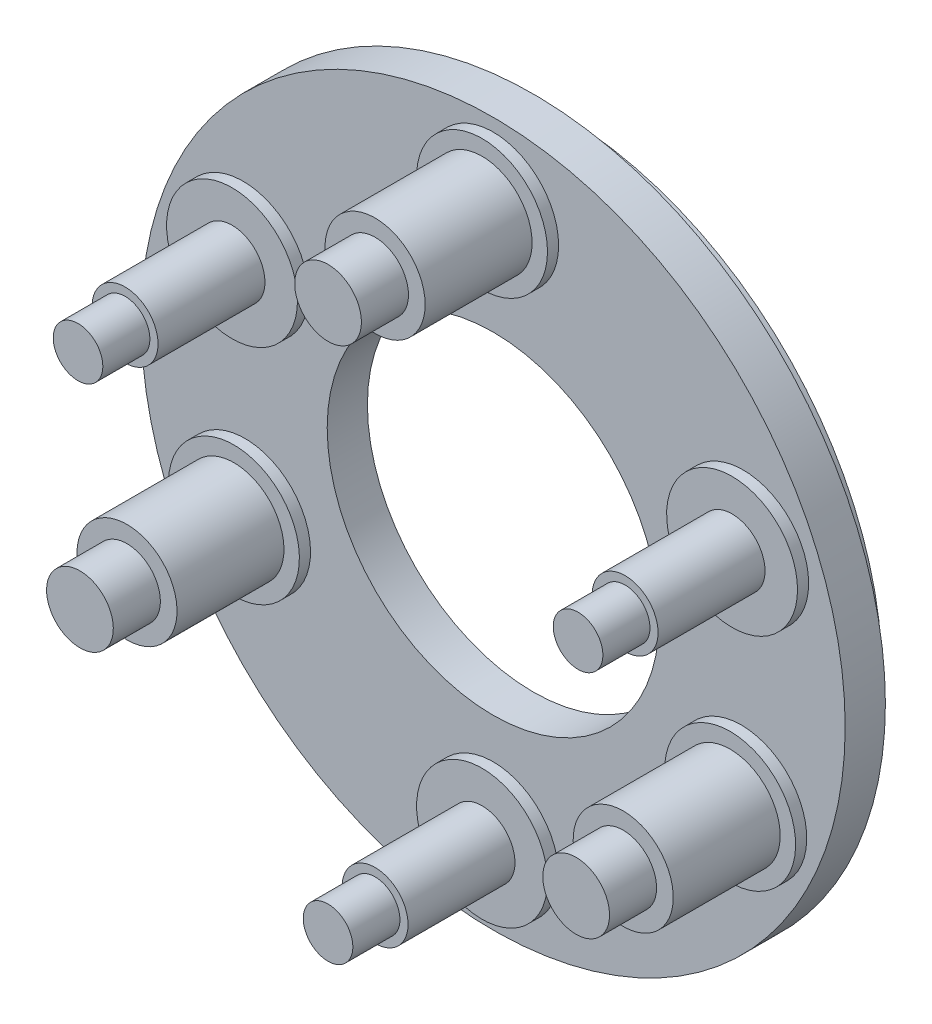
from build123d import *

# Parameters (mm, degrees)
SKETCH1_R                        = 10.4521
SKETCH1_R_2                      = 4.9276
BASE_DEPTH                       = 1.1938
SKETCH2_R                        = 9.6393
SKETCH2_R_2                      = 8.89
TRACK_DEPTH                      = 0.7112
SKETCH3_R                        = 1.9431
PLATFORM_A1_DEPTH                = 0.3302
SKETCH4_R                        = 1.4859
PLATFORM_A2_DEPTH                = 3.175
SKETCH5_R                        = 0.9906
PLATFORM_A3_DEPTH                = 1.397
CCW_PATTERN_FOR_PLATFORM_A_COUNT = 2
CCW_PATTERN_FOR_PLATFORM_A_ANGLE = 115
CW_PATTERN_FOR_PLATFORM_A_COUNT  = 2
CW_PATTERN_FOR_PLATFORM_A_ANGLE  = 115
SKETCH6_R                        = 1.9431
PLATFORM_B1_DEPTH                = 0.3302
SKETCH7_R                        = 0.9779
PLATFORM_B2_DEPTH                = 3.175
SKETCH8_R                        = 0.7366
PLATFORM_B3_DEPTH                = 1.397
CCW_PATTERN_FOR_PLATFORM_B_COUNT = 2
CCW_PATTERN_FOR_PLATFORM_B_ANGLE = 113
CW_PATTERN_FOR_PLATFORM_B_COUNT  = 2
CW_PATTERN_FOR_PLATFORM_B_ANGLE  = 113


with BuildPart() as part:
    # Sketch1 → Base (new body)
    with BuildSketch(Plane.XY):
        Circle(SKETCH1_R)
        Circle(SKETCH1_R_2, mode=Mode.SUBTRACT)
    extrude(amount=BASE_DEPTH)

    # Sketch2 → Track (add)
    with BuildSketch(Plane(origin=(0, 0, 0), x_dir=(-1, 0, 0), z_dir=(0, 0, -1))):
        Circle(SKETCH2_R)
        Circle(SKETCH2_R_2, mode=Mode.SUBTRACT)
    extrude(amount=TRACK_DEPTH)

    # Sketch3 → Platform A1 (add)
    with BuildSketch(Plane.XY.offset(1.1938)):
        with Locations((0, 8.128)):
            Circle(SKETCH3_R)
    platform_a1 = extrude(amount=PLATFORM_A1_DEPTH)

    # Sketch4 → Platform A2 (add)
    with BuildSketch(Plane.XY.offset(1.524)):
        with Locations((0, 8.128)):
            Circle(SKETCH4_R)
    platform_a2 = extrude(amount=PLATFORM_A2_DEPTH)

    # Sketch5 → Platform A3 (add)
    with BuildSketch(Plane.XY.offset(4.699)):
        with Locations((0, 8.128)):
            Circle(SKETCH5_R)
    platform_a3 = extrude(amount=PLATFORM_A3_DEPTH)

    # CCW pattern for platform A: Platform A1, Platform A2, Platform A3 ×2 about axis
    ccw_pattern_for_platform_a_axis = Axis((0, 0, 1.1938), (0, 0, 1))
    for i in range(1, CCW_PATTERN_FOR_PLATFORM_A_COUNT):
        add(platform_a1.rotate(ccw_pattern_for_platform_a_axis, i * CCW_PATTERN_FOR_PLATFORM_A_ANGLE / (CCW_PATTERN_FOR_PLATFORM_A_COUNT - 1)))
        add(platform_a2.rotate(ccw_pattern_for_platform_a_axis, i * CCW_PATTERN_FOR_PLATFORM_A_ANGLE / (CCW_PATTERN_FOR_PLATFORM_A_COUNT - 1)))
        add(platform_a3.rotate(ccw_pattern_for_platform_a_axis, i * CCW_PATTERN_FOR_PLATFORM_A_ANGLE / (CCW_PATTERN_FOR_PLATFORM_A_COUNT - 1)))

    # CW pattern for platform A: Platform A1, Platform A2, Platform A3 ×2 about axis
    cw_pattern_for_platform_a_axis = Axis((0, 0, 1.1938), (0, 0, -1))
    for i in range(1, CW_PATTERN_FOR_PLATFORM_A_COUNT):
        add(platform_a1.rotate(cw_pattern_for_platform_a_axis, i * CW_PATTERN_FOR_PLATFORM_A_ANGLE / (CW_PATTERN_FOR_PLATFORM_A_COUNT - 1)))
        add(platform_a2.rotate(cw_pattern_for_platform_a_axis, i * CW_PATTERN_FOR_PLATFORM_A_ANGLE / (CW_PATTERN_FOR_PLATFORM_A_COUNT - 1)))
        add(platform_a3.rotate(cw_pattern_for_platform_a_axis, i * CW_PATTERN_FOR_PLATFORM_A_ANGLE / (CW_PATTERN_FOR_PLATFORM_A_COUNT - 1)))

    # Sketch6 → Platform B1 (add)
    with BuildSketch(Plane.XY.offset(1.1938)):
        with Locations((0, -8.0645)):
            Circle(SKETCH6_R)
    platform_b1 = extrude(amount=PLATFORM_B1_DEPTH)

    # Sketch7 → Platform B2 (add)
    with BuildSketch(Plane.XY.offset(1.524)):
        with Locations((0, -8.0645)):
            Circle(SKETCH7_R)
    platform_b2 = extrude(amount=PLATFORM_B2_DEPTH)

    # Sketch8 → Platform B3 (add)
    with BuildSketch(Plane.XY.offset(4.699)):
        with Locations((0, -8.0645)):
            Circle(SKETCH8_R)
    platform_b3 = extrude(amount=PLATFORM_B3_DEPTH)

    # CCW pattern for platform B: Platform B1, Platform B2, Platform B3 ×2 about axis
    ccw_pattern_for_platform_b_axis = Axis((0, 0, 1.1938), (0, 0, 1))
    for i in range(1, CCW_PATTERN_FOR_PLATFORM_B_COUNT):
        add(platform_b1.rotate(ccw_pattern_for_platform_b_axis, i * CCW_PATTERN_FOR_PLATFORM_B_ANGLE / (CCW_PATTERN_FOR_PLATFORM_B_COUNT - 1)))
        add(platform_b2.rotate(ccw_pattern_for_platform_b_axis, i * CCW_PATTERN_FOR_PLATFORM_B_ANGLE / (CCW_PATTERN_FOR_PLATFORM_B_COUNT - 1)))
        add(platform_b3.rotate(ccw_pattern_for_platform_b_axis, i * CCW_PATTERN_FOR_PLATFORM_B_ANGLE / (CCW_PATTERN_FOR_PLATFORM_B_COUNT - 1)))

    # CW pattern for platform B: Platform B1, Platform B2, Platform B3 ×2 about axis
    cw_pattern_for_platform_b_axis = Axis((0, 0, 1.1938), (0, 0, -1))
    for i in range(1, CW_PATTERN_FOR_PLATFORM_B_COUNT):
        add(platform_b1.rotate(cw_pattern_for_platform_b_axis, i * CW_PATTERN_FOR_PLATFORM_B_ANGLE / (CW_PATTERN_FOR_PLATFORM_B_COUNT - 1)))
        add(platform_b2.rotate(cw_pattern_for_platform_b_axis, i * CW_PATTERN_FOR_PLATFORM_B_ANGLE / (CW_PATTERN_FOR_PLATFORM_B_COUNT - 1)))
        add(platform_b3.rotate(cw_pattern_for_platform_b_axis, i * CW_PATTERN_FOR_PLATFORM_B_ANGLE / (CW_PATTERN_FOR_PLATFORM_B_COUNT - 1)))


solid = part.part
